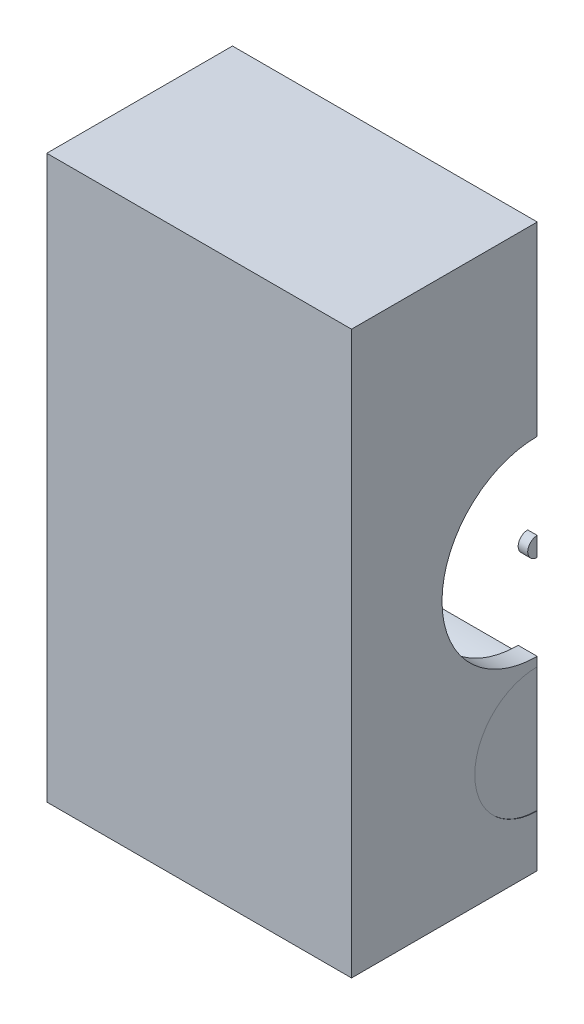
from build123d import *

# Parameters (mm, degrees)
ESQUISSE1_W             = 320
ESQUISSE1_H             = 590
ESQUISSE1_W_2           = 280
ESQUISSE1_H_2           = 550
BOSS_EXTRU_1_DEPTH      = 390
ESQUISSE2_W             = 280
ESQUISSE2_H             = 550
BOSS_EXTRU_2_DEPTH      = 20
ESQUISSE3_W             = 280
ESQUISSE3_H             = 550
BOSS_EXTRU_3_DEPTH      = 20
ESQUISSE4_R             = 100
ENL_V_MAT_EXTRU_1_DEPTH = 20
ESQUISSE5_R             = 65.55
ENL_V_MAT_EXTRU_2_DEPTH = 20
ESQUISSE7_R             = 68.55
ESQUISSE7_R_2           = 65.55
BOSS_EXTRU_4_DEPTH      = 140
ESQUISSE8_R             = 10
BOSS_EXTRU_5_DEPTH      = 10
ESQUISSE9_R             = 65.55
BOSS_EXTRU_6_DEPTH      = 1
ESQUISSE10_R            = 65.55
BOSS_EXTRU_7_DEPTH      = 1
ESQUISSE11_W            = 195
ESQUISSE11_H            = 590
ENL_V_MAT_EXTRU_3_DEPTH = 762.183289359


with BuildPart() as part:
    # Esquisse1 → Boss.-Extru.1 (new body)
    with BuildSketch(Plane.XY):
        with Locations((140, 275)):
            Rectangle(ESQUISSE1_W, ESQUISSE1_H)
        with Locations((140, 275)):
            Rectangle(ESQUISSE1_W_2, ESQUISSE1_H_2, mode=Mode.SUBTRACT)
    extrude(amount=BOSS_EXTRU_1_DEPTH)

    # Esquisse2 → Boss.-Extru.2 (add)
    with BuildSketch(Plane.XY.offset(390)):
        with Locations((140, 275)):
            Rectangle(ESQUISSE2_W, ESQUISSE2_H)
    extrude(amount=-BOSS_EXTRU_2_DEPTH)

    # Esquisse3 → Boss.-Extru.3 (add)
    with BuildSketch(Plane(origin=(0, 0, 0), x_dir=(-1, 0, 0), z_dir=(0, 0, -1))):
        with Locations((-140, 275)):
            Rectangle(ESQUISSE3_W, ESQUISSE3_H)
    extrude(amount=-BOSS_EXTRU_3_DEPTH)

    # Esquisse4 → Enlèv. mat.-Extru.1 (cut)
    with BuildSketch(Plane(origin=(300, 0, 0), x_dir=(0, 0, -1), z_dir=(1, 0, 0))):
        with Locations((-195, 275)):
            Circle(ESQUISSE4_R)
    extrude(amount=-ENL_V_MAT_EXTRU_1_DEPTH, mode=Mode.SUBTRACT)

    # Esquisse5 → Enlèv. mat.-Extru.2 (cut)
    with BuildSketch(Plane(origin=(300, 0, 0), x_dir=(0, 0, -1), z_dir=(1, 0, 0))):
        with Locations((-195, 100)):
            Circle(ESQUISSE5_R)
    extrude(amount=-ENL_V_MAT_EXTRU_2_DEPTH, mode=Mode.SUBTRACT)

    # Esquisse7 → Boss.-Extru.4 (add)
    with BuildSketch(Plane.ZY.offset(-280)):
        with Locations((195, 100)):
            Circle(ESQUISSE7_R)
        with Locations(Location((195, 100, 0), (0, 0, 180))):
            Circle(ESQUISSE7_R_2, mode=Mode.SUBTRACT)
    extrude(amount=BOSS_EXTRU_4_DEPTH)

    # Esquisse9 → Boss.-Extru.6 (add)
    with BuildSketch(Plane(origin=(299.5, 0, 0), x_dir=(0, 0, -1), z_dir=(1, 0, 0))):
        with Locations((-195, 100)):
            Circle(ESQUISSE9_R)
    extrude(amount=-BOSS_EXTRU_6_DEPTH)

    # Esquisse10 → Boss.-Extru.7 (add)
    with BuildSketch(Plane.ZY.offset(-140.5)):
        with Locations((195, 100)):
            Circle(ESQUISSE10_R)
    extrude(amount=-BOSS_EXTRU_7_DEPTH)


with BuildPart() as body_2:
    # Esquisse8 → Boss.-Extru.5 (new body)
    with BuildSketch(Plane(origin=(300, 0, 0), x_dir=(0, 0, -1), z_dir=(1, 0, 0))):
        with Locations((-195, 275)):
            Circle(ESQUISSE8_R)
    extrude(amount=-BOSS_EXTRU_5_DEPTH)


with BuildPart() as enl_v_mat_extru_3_tool:
    # Esquisse11 → Enlèv. mat.-Extru.3 (new, through all)
    with BuildSketch(Plane(origin=(300, 0, 0), x_dir=(0, 0, -1), z_dir=(1, 0, 0))):
        with Locations((-97.5, 275)):
            Rectangle(ESQUISSE11_W, ESQUISSE11_H)
    extrude(amount=-ENL_V_MAT_EXTRU_3_DEPTH)


with BuildPart() as part_1:
    add(part.part)

    # Enlèv. mat.-Extru.3: cut by enl_v_mat_extru_3_tool
    add(enl_v_mat_extru_3_tool.part, mode=Mode.SUBTRACT)


with BuildPart() as body_2_1:
    add(body_2.part)

    # Enlèv. mat.-Extru.3: cut by enl_v_mat_extru_3_tool
    add(enl_v_mat_extru_3_tool.part, mode=Mode.SUBTRACT)


solid = Compound([part_1.part, body_2_1.part])
